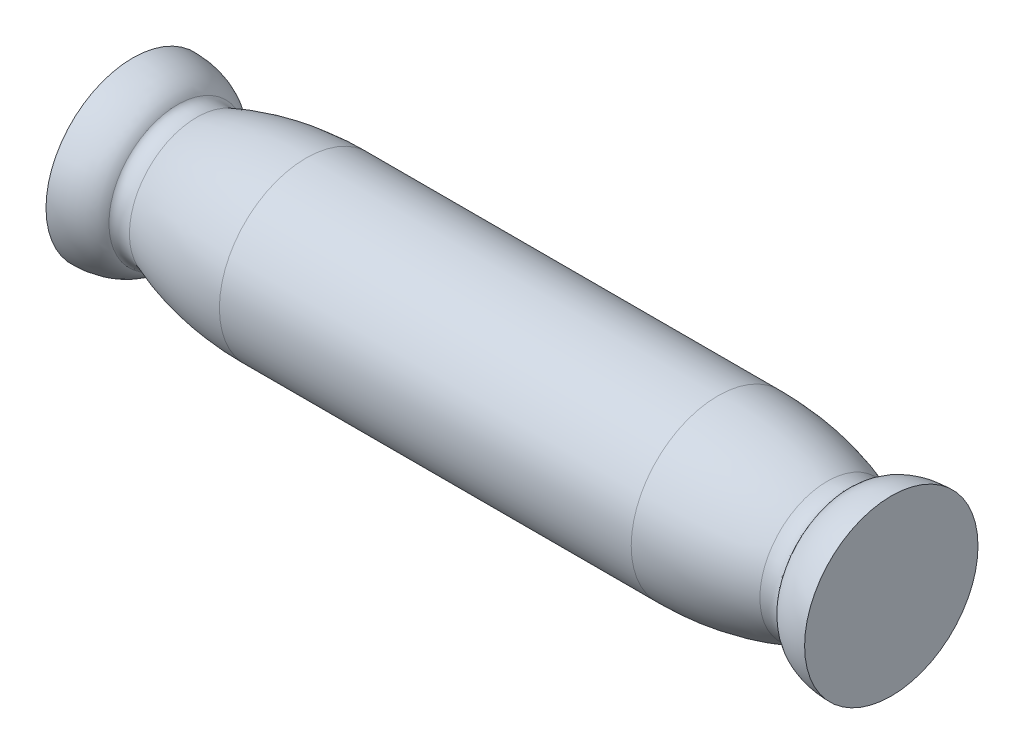
from build123d import *

# Parameters (mm, degrees)
SKETCH2_R           = 4
BOSS_EXTRUDE1_DEPTH = 35
CUT_EXTRUDE1_DEPTH  = 9.8


with BuildPart() as part:
    # Sketch2 → Boss-Extrude1 (new body)
    with BuildSketch(Plane(origin=(0, 0, 0), x_dir=(0, 0, -1), z_dir=(1, 0, 0))):
        Circle(SKETCH2_R)
    extrude(amount=BOSS_EXTRUDE1_DEPTH)

    # Sketch3 → Cut-Extrude1 (cut)
    with BuildSketch(Plane.ZY):
        with BuildLine():
            Line((-1.2489996, -1), (1.2489996, -1))
            ThreePointArc((1.2489996, -1), (0, 1.6), (-1.2489996, -1))
        make_face()
    extrude(amount=-CUT_EXTRUDE1_DEPTH, mode=Mode.SUBTRACT)

    # Sketch4 → Cut-Revolve1 (revolve, cut)
    with BuildSketch(Plane.XY):
        with BuildLine():
            Line((0, 4), (8, 4))
            add(Edge.make_bspline(
                [(8, 4), (5.194687526, 4), (2.956130498, 3.107691813)],
                knots=[4.71238898, 4.71238898, 4.71238898, 5.359264748, 5.359264748, 5.359264748], degree=2, weights=[1, 0.948148367, 1]))
            add(Edge.make_bspline(
                [(2.068059433, 3.164260662), (2.318713674, 2.853611956), (2.956130498, 3.107691813)],
                knots=[0, 0, 0, 1.038649512, 1.038649512, 1.038649512], degree=2, weights=[1, 0.868154497, 1]))
            add(Edge.make_bspline(
                [(2.068059433, 3.164260662), (1.597970656, 4), (0, 4)],
                knots=[3.440188633, 3.440188633, 3.440188633, 4.71238898, 4.71238898, 4.71238898], degree=2, weights=[1, 0.804418611, 1]))
        make_face()
        with BuildLine():
            Line((27, 4), (35, 4))
            add(Edge.make_bspline(
                [(35, 4), (33.402029344, 4), (32.931940567, 3.164260662)],
                knots=[1.570796327, 1.570796327, 1.570796327, 2.842996674, 2.842996674, 2.842996674], degree=2, weights=[1, 0.804418611, 1]))
            add(Edge.make_bspline(
                [(32.043869502, 3.107691813), (32.681286326, 2.853611956), (32.931940567, 3.164260662)],
                knots=[2.102943141, 2.102943141, 2.102943141, 3.141592654, 3.141592654, 3.141592654], degree=2, weights=[1, 0.868154497, 1]))
            add(Edge.make_bspline(
                [(32.043869502, 3.107691813), (29.805312474, 4), (27, 4)],
                knots=[4.065513213, 4.065513213, 4.065513213, 4.71238898, 4.71238898, 4.71238898], degree=2, weights=[1, 0.948148367, 1]))
        make_face()
    revolve(axis=Axis((0, 0, 0), (1, 0, 0)), mode=Mode.SUBTRACT)


solid = part.part
